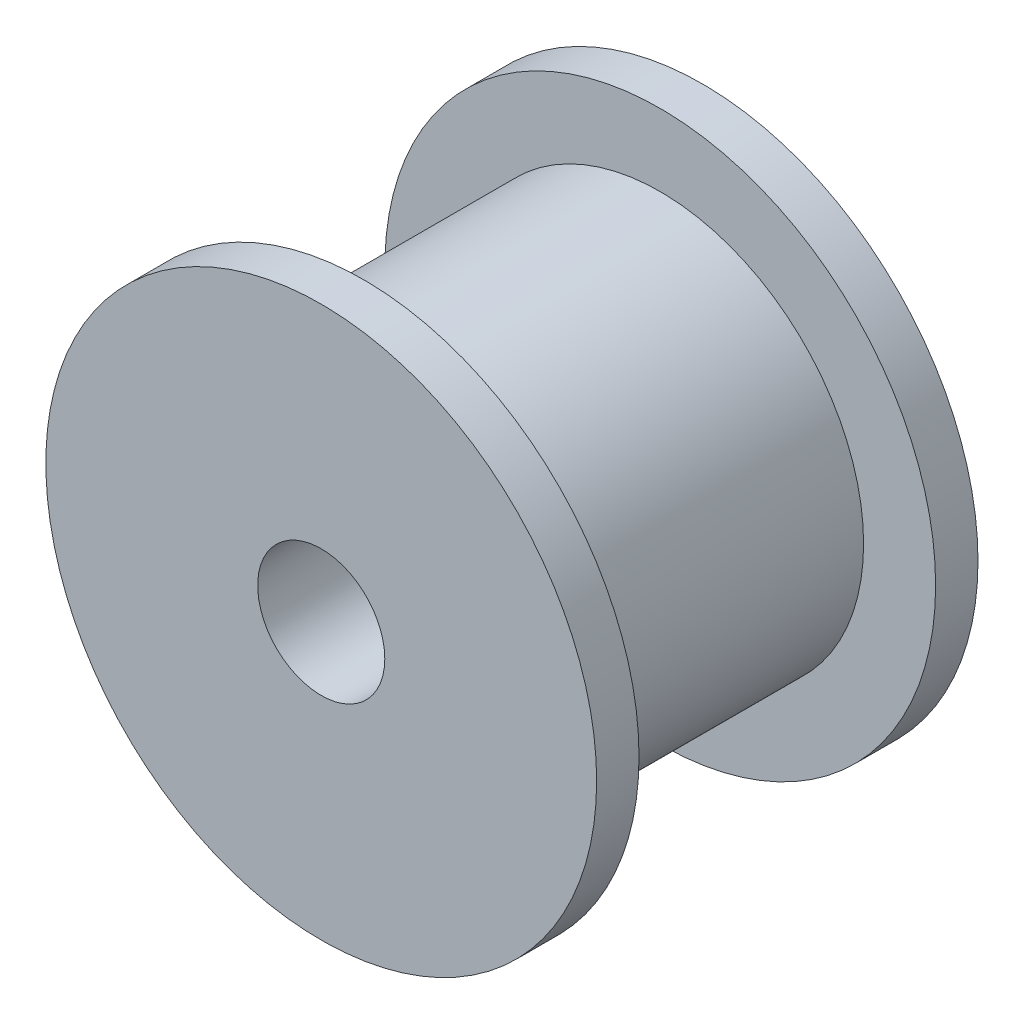
from build123d import *

# Parameters (mm, degrees)
SKETCH1_R           = 6.5
SKETCH1_R_2         = 1.5
BOSS_EXTRUDE1_DEPTH = 1
SKETCH2_R           = 4.8
SKETCH2_R_2         = 1.5
BOSS_EXTRUDE2_DEPTH = 7
SKETCH3_R           = 6.5
SKETCH3_R_2         = 1.5
BOSS_EXTRUDE3_DEPTH = 1


with BuildPart() as part:
    # Sketch1 → Boss-Extrude1 (new body)
    with BuildSketch(Plane.XY):
        Circle(SKETCH1_R)
        Circle(SKETCH1_R_2, mode=Mode.SUBTRACT)
    extrude(amount=BOSS_EXTRUDE1_DEPTH)

    # Sketch2 → Boss-Extrude2 (add)
    with BuildSketch(Plane.XY.offset(1)):
        Circle(SKETCH2_R)
        Circle(SKETCH2_R_2, mode=Mode.SUBTRACT)
    extrude(amount=BOSS_EXTRUDE2_DEPTH)

    # Sketch3 → Boss-Extrude3 (add)
    with BuildSketch(Plane.XY.offset(8)):
        Circle(SKETCH3_R)
        Circle(SKETCH3_R_2, mode=Mode.SUBTRACT)
    extrude(amount=BOSS_EXTRUDE3_DEPTH)


solid = part.part
